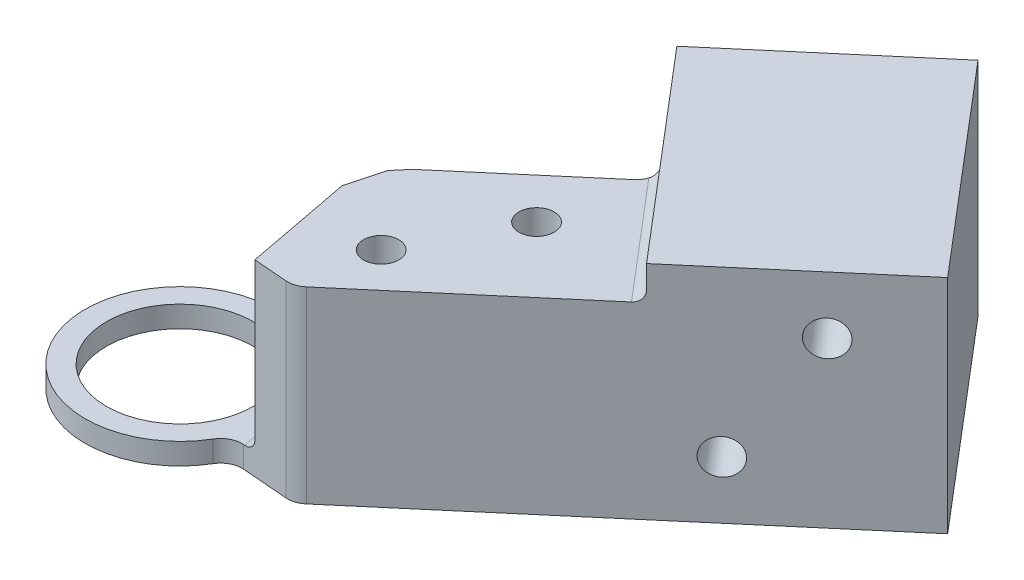
from build123d import *

# Parameters (mm, degrees)
SKETCH1_R                      = 12.5
BOSS_EXTRUDE1_DEPTH            = 17.6
SKETCH2_R                      = 6.875
CUT_EXTRUDE1_DEPTH             = 50.8
SKETCH3_R                      = 8.875
CUT_EXTRUDE3_DEPTH             = 15.6
CUT_EXTRUDE4_DEPTH             = 18.6
BOSS_EXTRUDE2_DEPTH            = 17.6
FILLET1_R                      = 4
SKETCH6_W                      = 25
SKETCH6_H                      = 20.775
BOSS_EXTRUDE3_DEPTH            = 20
M4X0_7_TAPPED_HOLE2_AT_2_COUNT = 2
M4X0_7_TAPPED_HOLE2_AT_2_PITCH = 12.206555616
M4X0_7_TAPPED_HOLE1_D          = 3.3
M4X0_7_TAPPED_HOLE1_DEPTH      = 7
M4X0_7_TAPPED_HOLE1_TIP        = 0.991420021
FILLET4_R                      = 1
FILLET6_R                      = 1
FILLET7_R                      = 2
CUT_EXTRUDE6_DEPTH             = 15.6
FILLET8_R                      = 5
BOSS_EXTRUDE4_DEPTH            = 17.6
CUT_EXTRUDE8_DEPTH             = 18.6000001
CUT_EXTRUDE9_DEPTH             = 18.6000001
CUT_EXTRUDE10_DEPTH            = 15.6
FILLET10_R                     = 1
FILLET12_R                     = 1
FILLET13_R                     = 2


with BuildPart() as part:
    # Sketch1 → Boss-Extrude1 (new body)
    with BuildSketch(Plane(origin=(0, 0, 0), x_dir=(1, 0, 0), z_dir=(0, 1, 0))):
        Circle(SKETCH1_R)
    extrude(amount=BOSS_EXTRUDE1_DEPTH)

    # Sketch2 → Cut-Extrude1 (cut)
    with BuildSketch(Plane(origin=(0, 17.6, 0), x_dir=(1, 0, 0), z_dir=(0, 1, 0))):
        Circle(SKETCH2_R)
    extrude(amount=-CUT_EXTRUDE1_DEPTH, mode=Mode.SUBTRACT)

    # Sketch3 → Cut-Extrude3 (cut)
    with BuildSketch(Plane(origin=(0, 17.6, 0), x_dir=(1, 0, 0), z_dir=(0, 1, 0))):
        Circle(SKETCH3_R)
    extrude(amount=-CUT_EXTRUDE3_DEPTH, mode=Mode.SUBTRACT)

    # Sketch4 → Cut-Extrude4 (cut, through all)
    with BuildSketch(Plane(origin=(0, 17.6, 0), x_dir=(1, 0, 0), z_dir=(0, 1, 0))):
        with BuildLine():
            ThreePointArc((-3.035428772, 8.339772009), (2.668763971, 8.464237938), (7.269974393, 5.090490873))
            Line((7.269974393, 5.090490873), (10.239400554, 7.169705454))
            ThreePointArc((10.239400554, 7.169705454), (3.758822494, 11.921461884), (-4.275251792, 11.74615776))
            Line((-4.275251792, 11.74615776), (-3.035428772, 8.339772009))
        make_face()
    extrude(amount=-CUT_EXTRUDE4_DEPTH, mode=Mode.SUBTRACT)

    # Sketch5 → Boss-Extrude2 (add, through all)
    with BuildSketch(Plane(origin=(0, 17.6, 0), x_dir=(1, 0, 0), z_dir=(0, 1, 0))):
        with BuildLine():
            Line((8.100371818, -9.520187835), (32.472052675, 11.216764019))
            Line((32.472052675, 11.216764019), (23.399636239, 21.879374394))
            Line((23.399636239, 21.879374394), (10.717665156, 11.088759446))
            Line((10.717665156, 11.088759446), (10.239400554, 7.169705454))
            ThreePointArc((10.239400554, 7.169705454), (12.398586499, -1.589041484), (8.100371818, -9.520187835))
        make_face()
    extrude(amount=-BOSS_EXTRUDE2_DEPTH)

    # Fillet1
    fillet1_edges = [part.edges().sort_by_distance(p)[0] for p in [
        (-3.035428772, 9.8, -8.339772009),
    ]]
    fillet(fillet1_edges, radius=FILLET1_R)

    # Sketch6 → Boss-Extrude3 (add)
    with BuildSketch(Plane(origin=(24.371680857, 0, -20.736951854), x_dir=(-0.648029745, 0, -0.761615027), z_dir=(0.761615027, 0, -0.648029745))):
        with Locations((0, 10.3875)):
            Rectangle(SKETCH6_W, SKETCH6_H)
    extrude(amount=BOSS_EXTRUDE3_DEPTH)

    # Sketch9 → M4x0.7 Tapped Hole2 (revolve, cut)
    with BuildSketch(Plane(origin=(25.410689361, 15.3875, -38.033496634), x_dir=(-0.761615027, 0, 0.648029745), z_dir=(0, 1, 0))):
        Polygon((0, 0), (0, 7.991420021), (1.65, 7), (1.65, 0), align=None)
    m4x0_7_tapped_hole2 = revolve(axis=Axis((21.295700477, 15.3875, -42.869752054), (0.648029745, 0, 0.761615027)), mode=Mode.SUBTRACT)

    # M4x0.7 Tapped Hole2 at 2: M4x0.7 Tapped Hole2 ×2
    with Locations(*[Vector(-0.436757539, -0.819231921, 0.371620657) * (i * M4X0_7_TAPPED_HOLE2_AT_2_PITCH) for i in range(1, M4X0_7_TAPPED_HOLE2_AT_2_COUNT)]):
        add(m4x0_7_tapped_hole2, mode=Mode.SUBTRACT)

    # Mirror1: M4x0.7 Tapped Hole2 across plane
    add(m4x0_7_tapped_hole2.mirror(Plane(origin=(0, 0, 0), x_dir=(-0.761615027, 0, 0.648029745), z_dir=(-0.648029745, 0, -0.761615027))), mode=Mode.SUBTRACT)

    # Mirror1 copy 1 sketch → Mirror1 copy 1 (revolve, cut)
    with BuildSketch(Plane(origin=(36.280127809, 5.3875, -14.456912746), x_dir=(-0.761615027, 0, 0.648029745), z_dir=(0, 1, 0))):
        Polygon((0, 0), (0, -7.991420021), (1.65, -7), (1.65, 0), align=None)
    revolve(axis=Axis((40.395116693, 5.3875, -9.620657326), (0.648029745, 0, 0.761615027)), mode=Mode.SUBTRACT)

    # M4x0.7 Tapped Hole1
    with Locations(Plane(origin=(0, 17.6, 0), x_dir=(1, 0, 0), z_dir=(0, 1, 0))):
        with Locations((20.785019884, 12.607162838), (15.760988598, 3.080405276)):
            Hole(M4X0_7_TAPPED_HOLE1_D / 2, depth=M4X0_7_TAPPED_HOLE1_DEPTH)
            with Locations((0, 0, -(M4X0_7_TAPPED_HOLE1_DEPTH + M4X0_7_TAPPED_HOLE1_TIP / 2))):  # 118° drill point
                Cone(0, M4X0_7_TAPPED_HOLE1_D / 2, M4X0_7_TAPPED_HOLE1_TIP, mode=Mode.SUBTRACT)

    # Fillet4
    fillet4_edges = [part.edges().sort_by_distance(p)[0] for p in [
        (27.935844457, 17.6, -16.548069207),
    ]]
    fillet(fillet4_edges, radius=FILLET4_R)

    # Fillet6
    fillet6_edges = [part.edges().sort_by_distance(p)[0] for p in [
        (-3.035428772, 1, -8.339772009),
        (7.269974393, 1, -5.090490873),
    ]]
    fillet(fillet6_edges, radius=FILLET6_R)

    # Fillet7
    fillet7_edges = [part.edges().sort_by_distance(p)[0] for p in [
        (23.399636239, 8.8, -21.879374394),
    ]]
    fillet(fillet7_edges, radius=FILLET7_R)

    # Sketch13 → Cut-Extrude6 (cut)
    with BuildSketch(Plane(origin=(0, 17.6, 0), x_dir=(1, 0, 0), z_dir=(0, 1, 0))):
        Polygon((8.029469851, 3.780640013), (11.336580589, 16.160351586), (5.704740036, 6.798644433), (7.043250731, 5.399837418), align=None)
    extrude(amount=-CUT_EXTRUDE6_DEPTH, mode=Mode.SUBTRACT)

    # Fillet8
    fillet8_edges = [part.edges().sort_by_distance(p)[0] for p in [
        (8.029469851, 9.8, -3.780640013),
    ]]
    fillet(fillet8_edges, radius=FILLET8_R)

    # Sketch14 → Boss-Extrude4 (add)
    with BuildSketch(Plane(origin=(0, 17.6, 0), x_dir=(1, 0, 0), z_dir=(0, 1, 0))):
        Polygon((8.634649617, 6.046046752), (9.642801422, 9.819923576), (10.717665156, 11.088759446), (10.239400554, 7.169705454), align=None)
    extrude(amount=-BOSS_EXTRUDE4_DEPTH)

    # Sketch15 → Cut-Extrude8 (cut, through all)
    with BuildSketch(Plane(origin=(0, 17.6, 0), x_dir=(1, 0, 0), z_dir=(0, 1, 0))):
        with BuildLine():
            Line((8.100371818, -9.520187835), (11.149703632, -6.925625425))
            Line((11.149703632, -6.925625425), (8.182097481, -3.437863553))
            ThreePointArc((8.182097481, -3.437863553), (-6.728578701, -5.787214672), (-2.175290984, 8.6042858))
            Line((-2.175290984, 8.6042858), (-4.275251792, 11.74615776))
            ThreePointArc((-4.275251792, 11.74615776), (-10.803807178, -6.287109865), (8.100371818, -9.520187835))
        make_face()
    extrude(amount=-CUT_EXTRUDE8_DEPTH, mode=Mode.SUBTRACT)

    # Sketch16 → Cut-Extrude9 (cut, through all)
    with BuildSketch(Plane(origin=(0, 17.6, 0), x_dir=(1, 0, 0), z_dir=(0, 1, 0))):
        Polygon((8.182097481, -3.437863553), (11.149703632, -6.925625425), (14.637465505, -3.958019274), align=None)
    extrude(amount=-CUT_EXTRUDE9_DEPTH, mode=Mode.SUBTRACT)

    # Sketch17 → Cut-Extrude10 (cut)
    with BuildSketch(Plane(origin=(0, 17.6, 0), x_dir=(1, 0, 0), z_dir=(0, 1, 0))):
        Polygon((8.738215958, 6.433733022), (10.661432187, -3.637641494), (8.182097481, -3.437863553), (7.951366346, 5.910414581), align=None)
    extrude(amount=-CUT_EXTRUDE10_DEPTH, mode=Mode.SUBTRACT)

    # Fillet10
    fillet10_edges = [part.edges().sort_by_distance(p)[0] for p in [
        (8.634649617, 1, -6.046046752),
    ]]
    fillet(fillet10_edges, radius=FILLET10_R)

    # Fillet12
    fillet12_edges = [part.edges().sort_by_distance(p)[0] for p in [
        (9.699824072, 2, -1.398045764),
    ]]
    fillet(fillet12_edges, radius=FILLET12_R)

    # Fillet13
    fillet13_edges = [part.edges().sort_by_distance(p)[0] for p in [
        (8.182097481, 1, 3.437863553),
        (14.637465505, 8.8, 3.958019274),
    ]]
    fillet(fillet13_edges, radius=FILLET13_R)


solid = part.part
